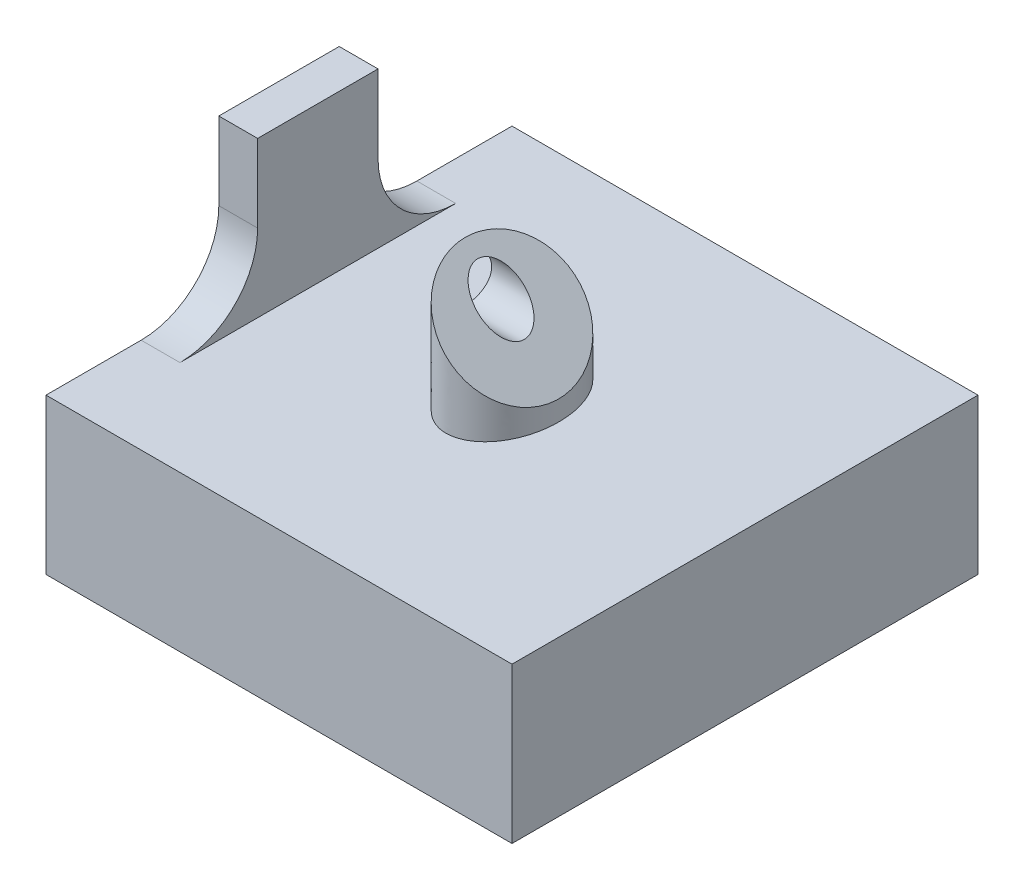
from build123d import *

# Parameters (mm, degrees)
SKETCH2_W               = 60
SKETCH2_H               = 60
BOSS_EXTRUDE1_DEPTH     = 20
SKETCH9_R               = 8.5
SKETCH10_RX             = 8.5
SKETCH10_RY             = 6.01040764
SKETCH12_R              = 3
CUT_EXTRUDE1_DEPTH      = 61
SKETCH13_R              = 3
CUT_EXTRUDE2_DEPTH      = 21
SKETCH15_W              = 5
SKETCH15_H              = 15.5
BOSS_EXTRUDE2_DEPTH     = 20
FILLET1_R               = 10
SKETCH17_W              = 28.111929505
SKETCH17_H              = 1
CUT_EXTRUDE3_DEPTH      = 23
CUT_EXTRUDE3_DEPTH_BACK = 3


with BuildPart() as part:
    # Sketch2 → Boss-Extrude1 (new body)
    with BuildSketch(Plane(origin=(0, 0, 0), x_dir=(1, 0, 0), z_dir=(0, 1, 0))):
        Rectangle(SKETCH2_W, SKETCH2_H)
    extrude(amount=BOSS_EXTRUDE1_DEPTH)

    # Sketch9 → Loft1 section 0
    with BuildSketch(Plane(origin=(15, 15, 0), x_dir=(0, 0, -1), z_dir=(0.707106781, 0.707106781, 0))):
        with Locations((0, 21.213203436)):
            Circle(SKETCH9_R)
    # Sketch10 → Loft1 section 1
    with BuildSketch(Plane(origin=(0, 20, 0), x_dir=(1, 0, 0), z_dir=(0, 1, 0))):
        with Locations(Location((0, 0), (0, 0, 90))):
            Ellipse(SKETCH10_RX, SKETCH10_RY)
    loft()

    # Sketch12 → Cut-Extrude1 (cut, through all)
    with BuildSketch(Plane(origin=(30, 0, 0), x_dir=(0, 0, -1), z_dir=(1, 0, 0))):
        with Locations((0, 30)):
            Circle(SKETCH12_R)
    extrude(amount=-CUT_EXTRUDE1_DEPTH, mode=Mode.SUBTRACT)

    # Sketch13 → Cut-Extrude2 (cut, through all)
    with BuildSketch(Plane(origin=(0, 20, 0), x_dir=(1, 0, 0), z_dir=(0, 1, 0))):
        Circle(SKETCH13_R)
    extrude(amount=-CUT_EXTRUDE2_DEPTH, mode=Mode.SUBTRACT)

    # Sketch15 → Boss-Extrude2 (add)
    with BuildSketch(Plane(origin=(0, 20, 0), x_dir=(1, 0, 0), z_dir=(0, 1, 0))):
        with Locations((-27.5, 0)):
            Rectangle(SKETCH15_W, SKETCH15_H)
    extrude(amount=BOSS_EXTRUDE2_DEPTH)

    # Fillet1
    fillet1_edges = [part.edges().sort_by_distance(p)[0] for p in [
        (-27.5, 20, 7.75),
        (-27.5, 20, -7.75),
    ]]
    fillet(fillet1_edges, radius=FILLET1_R)

    # Sketch17 → Cut-Extrude3 (cut, two sides)
    with BuildSketch(Plane(origin=(-8.98959236, 8.98959236, 0), x_dir=(0, 0, 1), z_dir=(-0.707106781, 0.707106781, 0))) as cut_extrude3_sk:
        with Locations((0.173110945, 20.713203436)):
            Rectangle(SKETCH17_W, SKETCH17_H)
    extrude(amount=CUT_EXTRUDE3_DEPTH, mode=Mode.SUBTRACT)
    extrude(cut_extrude3_sk.sketch, amount=-CUT_EXTRUDE3_DEPTH_BACK, mode=Mode.SUBTRACT)


solid = part.part
